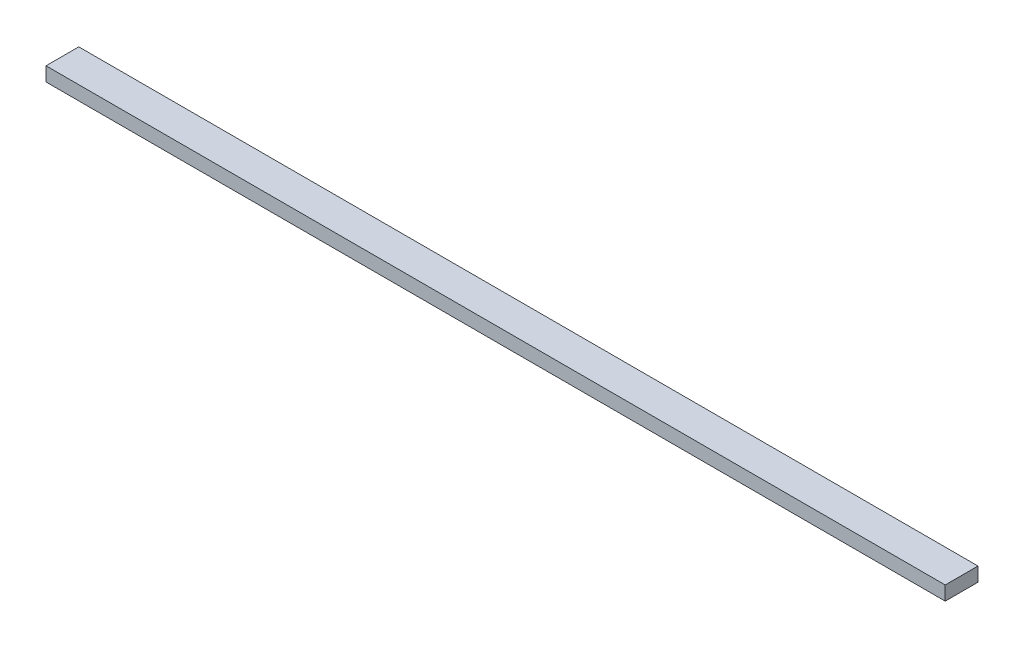
from build123d import *

# Parameters (mm, degrees)
SKETCH1_W           = 2438.4
SKETCH1_H           = 88.9
BOSS_EXTRUDE1_DEPTH = 38.1


with BuildPart() as part:
    # Sketch1 → Boss-Extrude1 (new body)
    with BuildSketch(Plane(origin=(0, 0, 0), x_dir=(1, 0, 0), z_dir=(0, 1, 0))):
        with Locations((1219.2, -44.45)):
            Rectangle(SKETCH1_W, SKETCH1_H)
    extrude(amount=BOSS_EXTRUDE1_DEPTH)


solid = part.part
